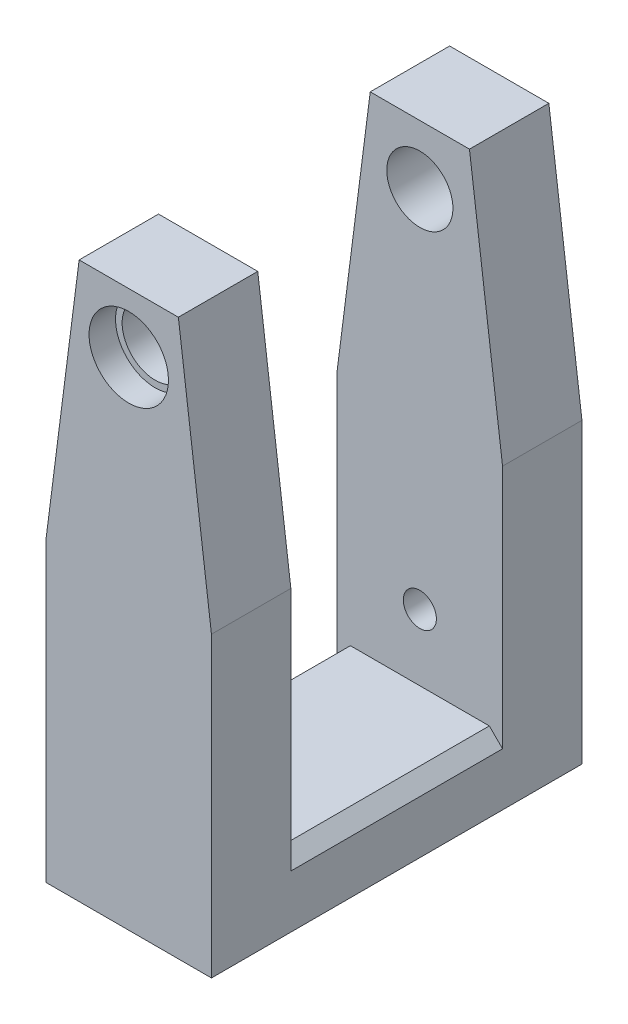
from build123d import *

# Parameters (mm, degrees)
BOSS_EXTRUDE1_DEPTH                     = 56
SKETCH2_W                               = 32
SKETCH2_H                               = 74
CUT_EXTRUDE1_DEPTH                      = 56
CHAMFER1_SIZE                           = 2
CBORE_FOR_M6_HEX_HEAD_BOLT1_D           = 10
CBORE_FOR_M6_HEX_HEAD_BOLT1_DEPTH       = 20
CBORE_FOR_M6_HEX_HEAD_BOLT1_CBORE_D     = 12
CBORE_FOR_M6_HEX_HEAD_BOLT1_CBORE_DEPTH = 4
CBORE_FOR_M6_HEX_HEAD_BOLT1_TIP         = 3.004303095
CBORE_FOR_M6_HEX_HEAD_BOLT3_D           = 10
CBORE_FOR_M6_HEX_HEAD_BOLT3_DEPTH       = 20
CBORE_FOR_M6_HEX_HEAD_BOLT3_CBORE_D     = 12
CBORE_FOR_M6_HEX_HEAD_BOLT3_CBORE_DEPTH = 4
CBORE_FOR_M6_HEX_HEAD_BOLT3_TIP         = 3.004303095
M6X1_0_TAPPED_HOLE1_D                   = 5
M6X1_0_TAPPED_HOLE1_DEPTH               = 27
M6X1_0_TAPPED_HOLE1_TIP                 = 1.502151548


with BuildPart() as part:
    # Sketch1 → Boss-Extrude1 (new body)
    with BuildSketch(Plane.XY):
        Polygon((0, 0), (12.5, 0), (12.5, 45), (7.5, 84), (-7.5, 84), (-12.5, 45), (-12.5, 0), align=None)
    extrude(amount=BOSS_EXTRUDE1_DEPTH)

    # Sketch2 → Cut-Extrude1 (cut)
    with BuildSketch(Plane(origin=(12.5, 0, 0), x_dir=(0, 0, -1), z_dir=(1, 0, 0))):
        with Locations((-28, 47)):
            Rectangle(SKETCH2_W, SKETCH2_H)
    extrude(amount=-CUT_EXTRUDE1_DEPTH, mode=Mode.SUBTRACT)

    # Chamfer1
    chamfer1_edges = [part.edges().sort_by_distance(p)[0] for p in [
        (-12.5, 10, 28),
        (12.5, 10, 28),
    ]]
    chamfer(chamfer1_edges, length=CHAMFER1_SIZE)

    # CBORE for M6 Hex Head Bolt1
    with Locations(Plane.XY.offset(56)):
        with Locations((0, 75)):
            CounterBoreHole(CBORE_FOR_M6_HEX_HEAD_BOLT1_D / 2, CBORE_FOR_M6_HEX_HEAD_BOLT1_CBORE_D / 2, CBORE_FOR_M6_HEX_HEAD_BOLT1_CBORE_DEPTH, depth=CBORE_FOR_M6_HEX_HEAD_BOLT1_DEPTH)
            with Locations((0, 0, -(CBORE_FOR_M6_HEX_HEAD_BOLT1_DEPTH + CBORE_FOR_M6_HEX_HEAD_BOLT1_TIP / 2))):  # 118° drill point
                Cone(0, CBORE_FOR_M6_HEX_HEAD_BOLT1_D / 2, CBORE_FOR_M6_HEX_HEAD_BOLT1_TIP, mode=Mode.SUBTRACT)

    # CBORE for M6 Hex Head Bolt3
    with Locations(Plane(origin=(0, 0, 0), x_dir=(-1, 0, 0), z_dir=(0, 0, -1))):
        with Locations((0, 75)):
            CounterBoreHole(CBORE_FOR_M6_HEX_HEAD_BOLT3_D / 2, CBORE_FOR_M6_HEX_HEAD_BOLT3_CBORE_D / 2, CBORE_FOR_M6_HEX_HEAD_BOLT3_CBORE_DEPTH, depth=CBORE_FOR_M6_HEX_HEAD_BOLT3_DEPTH)
            with Locations((0, 0, -(CBORE_FOR_M6_HEX_HEAD_BOLT3_DEPTH + CBORE_FOR_M6_HEX_HEAD_BOLT3_TIP / 2))):  # 118° drill point
                Cone(0, CBORE_FOR_M6_HEX_HEAD_BOLT3_D / 2, CBORE_FOR_M6_HEX_HEAD_BOLT3_TIP, mode=Mode.SUBTRACT)

    # M6x1.0 Tapped Hole1
    with Locations(Plane(origin=(0, 20, 0), x_dir=(-1, 0, 0), z_dir=(0, 0, -1))):
        with Locations((0, 0)):
            Hole(M6X1_0_TAPPED_HOLE1_D / 2, depth=M6X1_0_TAPPED_HOLE1_DEPTH)
            with Locations((0, 0, -(M6X1_0_TAPPED_HOLE1_DEPTH + M6X1_0_TAPPED_HOLE1_TIP / 2))):  # 118° drill point
                Cone(0, M6X1_0_TAPPED_HOLE1_D / 2, M6X1_0_TAPPED_HOLE1_TIP, mode=Mode.SUBTRACT)


solid = part.part
